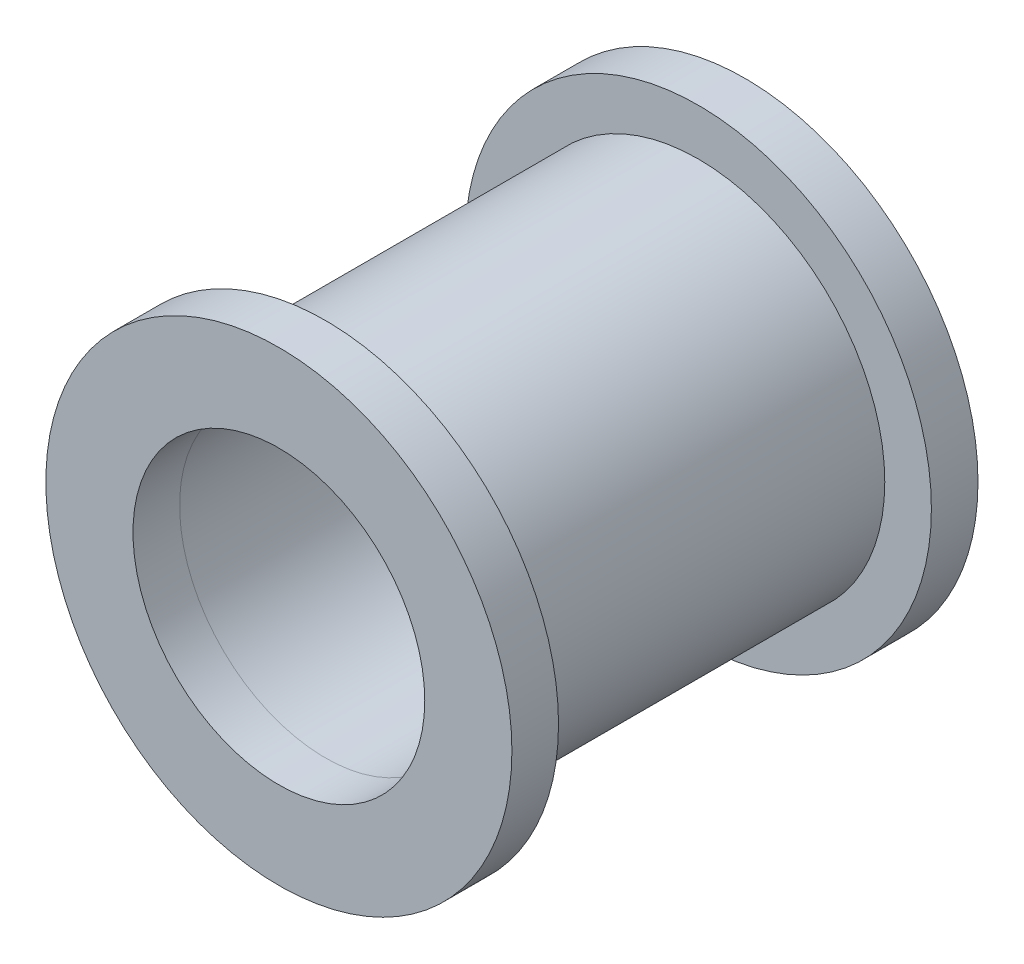
from build123d import *

# Parameters (mm, degrees)
SKETCH1_R           = 5.08
SKETCH1_R_2         = 3.9751
BOSS_EXTRUDE1_DEPTH = 5.08
SKETCH2_R           = 6.35
SKETCH2_R_2         = 3.9751
BOSS_EXTRUDE2_DEPTH = 1.27


with BuildPart() as part:
    # Sketch1 → Boss-Extrude1 (new body)
    with BuildSketch(Plane.XY):
        Circle(SKETCH1_R)
        Circle(SKETCH1_R_2, mode=Mode.SUBTRACT)
    boss_extrude1 = extrude(amount=-BOSS_EXTRUDE1_DEPTH)


with BuildPart() as body_2:
    # Sketch2 → Boss-Extrude2 (new body)
    with BuildSketch(Plane.XY):
        Circle(SKETCH2_R)
        Circle(SKETCH2_R_2, mode=Mode.SUBTRACT)
    boss_extrude2 = extrude(amount=BOSS_EXTRUDE2_DEPTH)


with BuildPart() as part_1:
    add(part.part)

    # Mirror1: Boss-Extrude1, Boss-Extrude2 across plane
    add(boss_extrude1.mirror(Plane.XY.offset(-5.08)))
    add(boss_extrude2.mirror(Plane.XY.offset(-5.08)))


solid = Compound([body_2.part, part_1.part])
